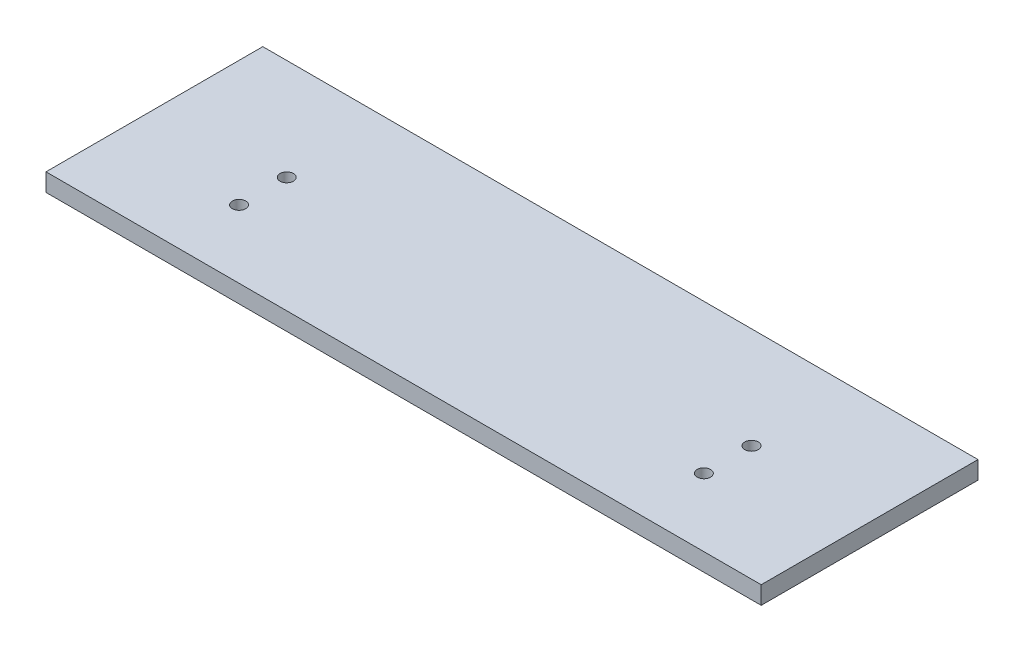
from build123d import *

# Parameters (mm, degrees)
SKETCH1_W           = 508
SKETCH1_H           = 153.999946
SKETCH1_R           = 4.7625
BOSS_EXTRUDE1_DEPTH = 12.7


with BuildPart() as part:
    # Sketch1 → Boss-Extrude1 (new body)
    with BuildSketch(Plane(origin=(0, 0, 0), x_dir=(1, 0, 0), z_dir=(0, 1, 0))):
        with Locations((60.70163918, 100.843256821)):
            Rectangle(SKETCH1_W, SKETCH1_H)
        with Locations((-104.39836082, 105.927631204)):
            Circle(SKETCH1_R, mode=Mode.SUBTRACT)
        with Locations((-104.39836082, 72.090673409)):
            Circle(SKETCH1_R, mode=Mode.SUBTRACT)
        with Locations((225.80163918, 105.876563154)):
            Circle(SKETCH1_R, mode=Mode.SUBTRACT)
        with Locations((225.80163918, 72.009896487)):
            Circle(SKETCH1_R, mode=Mode.SUBTRACT)
    extrude(amount=BOSS_EXTRUDE1_DEPTH)


solid = part.part
